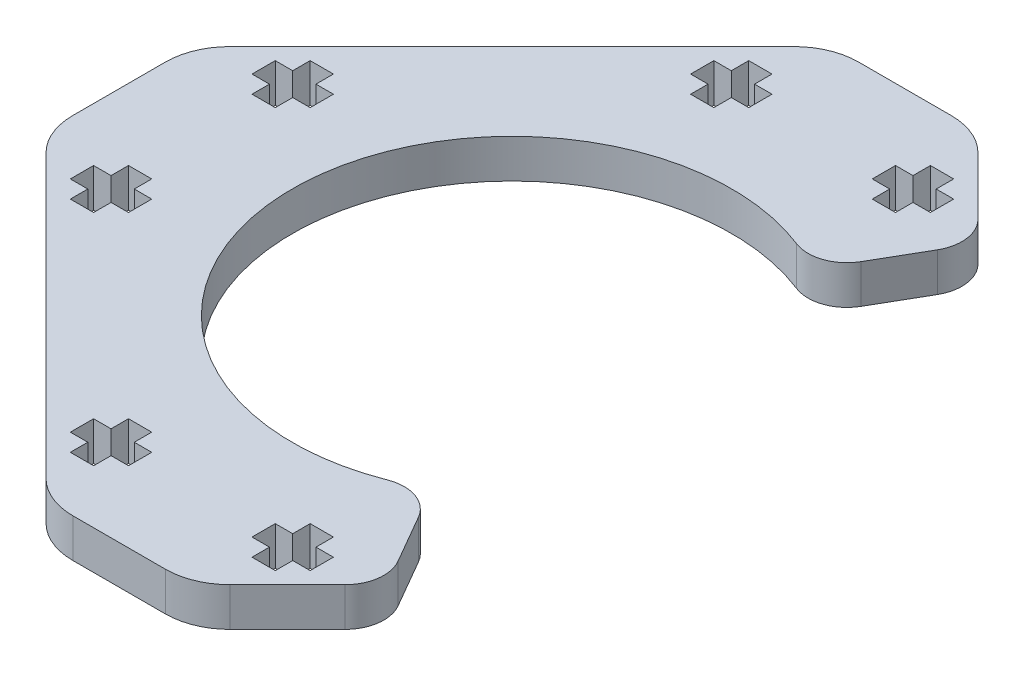
from build123d import *

# Parameters (mm, degrees)
BOSS_EXTRUDE1_DEPTH = 3
CUT_EXTRUDE1_DEPTH  = 4
FILLET1_R           = 3


with BuildPart() as part:
    # Sketch1 → Boss-Extrude1 (new body)
    with BuildSketch(Plane(origin=(0, 0, 0), x_dir=(1, 0, 0), z_dir=(0, 1, 0))):
        with BuildLine():
            Line((17.56993863, 22.86267454), (11.491487674, 28.941125497))
            ThreePointArc((11.491487674, 28.941125497), (9.869370929, 30.024989254), (7.955953768, 30.405591591))
            Line((7.955953768, 30.405591591), (0.784380892, 30.405591591))
            ThreePointArc((0.784380892, 30.405591591), (-1.129036269, 30.024989254), (-2.751153014, 28.941125497))
            Line((-2.751153014, 28.941125497), (-24.570958167, 7.121320344))
            ThreePointArc((-24.570958167, 7.121320344), (-25.654821924, 5.499203599), (-26.035424261, 3.585786438))
            Line((-26.035424261, 3.585786438), (-26.035424261, -3.585786438))
            ThreePointArc((-26.035424261, -3.585786438), (-25.654821924, -5.499203599), (-24.570958167, -7.121320344))
            Line((-24.570958167, -7.121320344), (-2.751153014, -28.941125497))
            ThreePointArc((-2.751153014, -28.941125497), (-1.129036269, -30.024989254), (0.784380892, -30.405591591))
            Line((0.784380892, -30.405591591), (7.955953768, -30.405591591))
            ThreePointArc((7.955953768, -30.405591591), (9.869370929, -30.024989254), (11.491487674, -28.941125497))
            Line((11.491487674, -28.941125497), (17.56993863, -22.86267454))
            Line((17.56993863, -22.86267454), (12.87016733, -14.722431864))
            ThreePointArc((12.87016733, -14.722431864), (-12.62983267, 0), (12.87016733, 14.722431864))
            Line((12.87016733, 14.722431864), (17.56993863, 22.86267454))
        make_face()
    extrude(amount=BOSS_EXTRUDE1_DEPTH)

    # Sketch2 → Cut-Extrude1 (cut, through all)
    with BuildSketch(Plane(origin=(0, 3, 0), x_dir=(1, 0, 0), z_dir=(0, 1, 0))):
        Polygon((-21.87983267, 7.929437252), (-21.87983267, 6.129437252), (-20.52983267, 6.129437252), (-20.52983267, 4.779437252), (-18.72983267, 4.779437252), (-18.72983267, 6.129437252), (-17.37983267, 6.129437252), (-17.37983267, 7.929437252), (-18.72983267, 7.929437252), (-18.72983267, 9.279437252), (-20.52983267, 9.279437252), (-20.52983267, 7.929437252), align=None)
        Polygon((-18.72983267, -4.779437252), (-20.52983267, -4.779437252), (-20.52983267, -6.129437252), (-21.87983267, -6.129437252), (-21.87983267, -7.929437252), (-20.52983267, -7.929437252), (-20.52983267, -9.279437252), (-18.72983267, -9.279437252), (-18.72983267, -7.929437252), (-17.37983267, -7.929437252), (-17.37983267, -6.129437252), (-18.72983267, -6.129437252), align=None)
        Polygon((12.299604582, 23.1), (13.649604582, 23.1), (13.649604582, 24.9), (12.299604582, 24.9), (12.299604582, 26.25), (10.499604582, 26.25), (10.499604582, 24.9), (9.149604582, 24.9), (9.149604582, 23.1), (10.499604582, 23.1), (10.499604582, 21.75), (12.299604582, 21.75), align=None)
        Polygon((30.62016733, -7.929437252), (30.62016733, -6.129437252), (29.27016733, -6.129437252), (29.27016733, -4.779437252), (27.47016733, -4.779437252), (27.47016733, -6.129437252), (26.12016733, -6.129437252), (26.12016733, -7.929437252), (27.47016733, -7.929437252), (27.47016733, -9.279437252), (29.27016733, -9.279437252), (29.27016733, -7.929437252), align=None)
        Polygon((-0.409269922, 24.9), (-1.759269922, 24.9), (-1.759269922, 26.25), (-3.559269922, 26.25), (-3.559269922, 24.9), (-4.909269922, 24.9), (-4.909269922, 23.1), (-3.559269922, 23.1), (-3.559269922, 21.75), (-1.759269922, 21.75), (-1.759269922, 23.1), (-0.409269922, 23.1), align=None)
        Polygon((30.62016733, 7.929437252), (29.27016733, 7.929437252), (29.27016733, 9.279437252), (27.47016733, 9.279437252), (27.47016733, 7.929437252), (26.12016733, 7.929437252), (26.12016733, 6.129437252), (27.47016733, 6.129437252), (27.47016733, 4.779437252), (29.27016733, 4.779437252), (29.27016733, 6.129437252), (30.62016733, 6.129437252), align=None)
        Polygon((-1.759269922, -26.25), (-1.759269922, -24.9), (-0.409269922, -24.9), (-0.409269922, -23.1), (-1.759269922, -23.1), (-1.759269922, -21.75), (-3.559269922, -21.75), (-3.559269922, -23.1), (-4.909269922, -23.1), (-4.909269922, -24.9), (-3.559269922, -24.9), (-3.559269922, -26.25), align=None)
        Polygon((12.299604582, -26.25), (12.299604582, -24.9), (13.649604582, -24.9), (13.649604582, -23.1), (12.299604582, -23.1), (12.299604582, -21.75), (10.499604582, -21.75), (10.499604582, -23.1), (9.149604582, -23.1), (9.149604582, -24.9), (10.499604582, -24.9), (10.499604582, -26.25), align=None)
    extrude(amount=-CUT_EXTRUDE1_DEPTH, mode=Mode.SUBTRACT)

    # Fillet1
    fillet1_edges = [part.edges().sort_by_distance(p)[0] for p in [
        (12.87016733, 1.5, 14.722431864),
        (17.56993863, 1.5, 22.86267454),
        (17.56993863, 1.5, -22.86267454),
        (12.87016733, 1.5, -14.722431864),
    ]]
    fillet(fillet1_edges, radius=FILLET1_R)


solid = part.part
